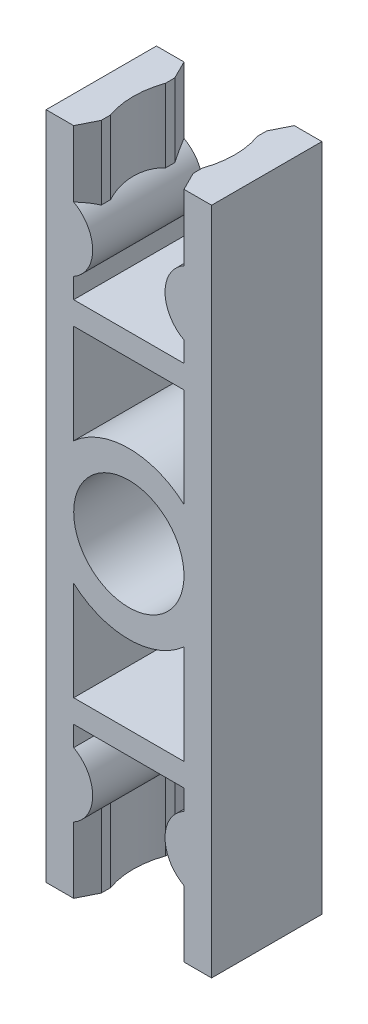
from build123d import *

# Parameters (mm, degrees)
EXTRUDE_1_DEPTH          = 6
SKETCH_2_R               = 3
CUT_EXTRUDE_1_DEPTH      = 20.684765683
EXTRUDE_2_REACH          = 25.907
PATTERN_CIRCULAR_1_COUNT = 2


with BuildPart() as part:
    # 草图1 → 凸台-拉伸1 (new body)
    with BuildSketch(Plane.XY):
        with BuildLine():
            Line((-4.5, 0), (-4.5, -18.2))
            Line((-4.5, -18.2), (-3, -18.2))
            Line((-3, -18.2), (-3, -14.6))
            ThreePointArc((-3, -14.6), (-1.968245837, -12.85), (-3, -11.1))
            Line((-3, -11.1), (-3, -10))
            Line((-3, -10), (3, -10))
            Line((3, -10), (3, -11.1))
            ThreePointArc((3, -11.1), (1.968245837, -12.85), (3, -14.6))
            Line((3, -14.6), (3, -18.2))
            Line((3, -18.2), (4.5, -18.2))
            Line((4.5, -18.2), (4.5, 0))
            ThreePointArc((4.5, 0), (0, 4.5), (-4.5, 0))
        make_face()
    extrude_1 = extrude(amount=EXTRUDE_1_DEPTH)

    # 草图2 → 切除-拉伸1 (cut, through all)
    with BuildSketch(Plane.XY):
        Circle(SKETCH_2_R)
        with BuildLine():
            Line((-3, -8.75), (-3, -3.354101966))
            ThreePointArc((-3, -3.354101966), (0, -4.5), (3, -3.354101966))
            Line((3, -3.354101966), (3, -8.75))
            Line((3, -8.75), (-3, -8.75))
        make_face()
    cut_extrude_1 = extrude(amount=CUT_EXTRUDE_1_DEPTH, mode=Mode.SUBTRACT)

    # 草图3 → 凸台-拉伸2 (add, up to next)
    with BuildSketch(Plane.XZ.offset(18.2), mode=Mode.PRIVATE) as extrude_2_sk1:
        with BuildLine():
            Line((-3, 6), (-3, 0))
            Line((-3, 0), (-2.5, 1))
            Line((-2.5, 1), (-2.5, 1.5))
            ThreePointArc((-2.5, 1.5), (-2.757359313, 3), (-2.5, 4.5))
            Line((-2.5, 4.5), (-2.5, 5))
            Line((-2.5, 5), (-3, 6))
        make_face()
    extrude_2_tool1 = extrude(extrude_2_sk1.sketch, amount=-EXTRUDE_2_REACH, mode=Mode.PRIVATE) - part.part
    # 草图3 → 凸台-拉伸2 (add, up to next)
    with BuildSketch(Plane.XZ.offset(18.2), mode=Mode.PRIVATE) as extrude_2_sk2:
        with BuildLine():
            Line((3, 0), (2.5, 1))
            Line((2.5, 1), (2.5, 1.5))
            ThreePointArc((2.5, 1.5), (2.757359313, 3), (2.5, 4.5))
            Line((2.5, 4.5), (2.5, 5))
            Line((2.5, 5), (3, 6))
            Line((3, 6), (3, 0))
        make_face()
    extrude_2_tool2 = extrude(extrude_2_sk2.sketch, amount=-EXTRUDE_2_REACH, mode=Mode.PRIVATE) - part.part
    extrude_2_1 = extrude_2_tool1.solids().sort_by_distance((-2.809362, -18.2, 3))[0]
    add(extrude_2_1)
    extrude_2_2 = extrude_2_tool2.solids().sort_by_distance((2.809362, -18.2, 3))[0]
    add(extrude_2_2)
    extrude_2 = extrude_2_1 + extrude_2_2  # 凸台-拉伸2 as one shape, for the pattern or mirror that repeats it

    # 阵列(圆周)1: 凸台-拉伸1, 切除-拉伸1, 凸台-拉伸2 ×2 about axis
    pattern_circular_1_axis = Axis((0, 0, 0), (0, 0, 1))
    add([extrude_1.rotate(pattern_circular_1_axis, i * 360 / PATTERN_CIRCULAR_1_COUNT) for i in range(1, PATTERN_CIRCULAR_1_COUNT)])
    add([cut_extrude_1.rotate(pattern_circular_1_axis, i * 360 / PATTERN_CIRCULAR_1_COUNT) for i in range(1, PATTERN_CIRCULAR_1_COUNT)], mode=Mode.SUBTRACT)
    add([extrude_2.rotate(pattern_circular_1_axis, i * 360 / PATTERN_CIRCULAR_1_COUNT) for i in range(1, PATTERN_CIRCULAR_1_COUNT)])


solid = part.part
